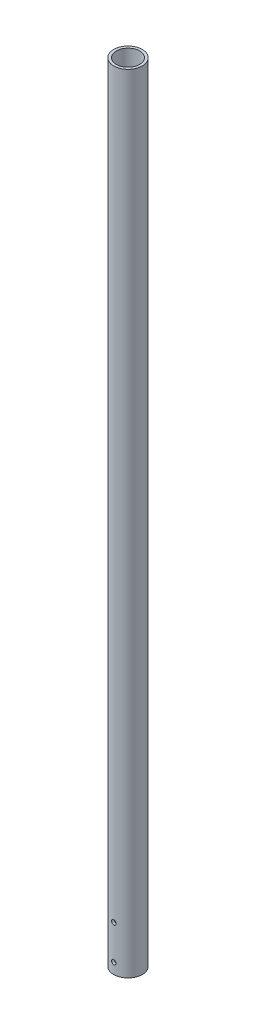
from build123d import *

# Parameters (mm, degrees)
SKETCH1_R               = 21.082
SKETCH1_R_2             = 17.272
BOSS_EXTRUDE1_DEPTH     = 1160.4625
F_1_4_CLEARANCE_HOLE1_D = 6.7564


with BuildPart() as part:
    # Sketch1 → Boss-Extrude1 (new body)
    with BuildSketch(Plane(origin=(0, 0, 0), x_dir=(1, 0, 0), z_dir=(0, 1, 0))):
        Circle(SKETCH1_R)
        Circle(SKETCH1_R_2, mode=Mode.SUBTRACT)
    extrude(amount=BOSS_EXTRUDE1_DEPTH)

    # 1/4 Clearance Hole1 (through all)
    with Locations(Plane.XY.offset(21.082)):
        with Locations((0, 15.875), (0, 66.675)):
            Hole(F_1_4_CLEARANCE_HOLE1_D / 2)


solid = part.part
